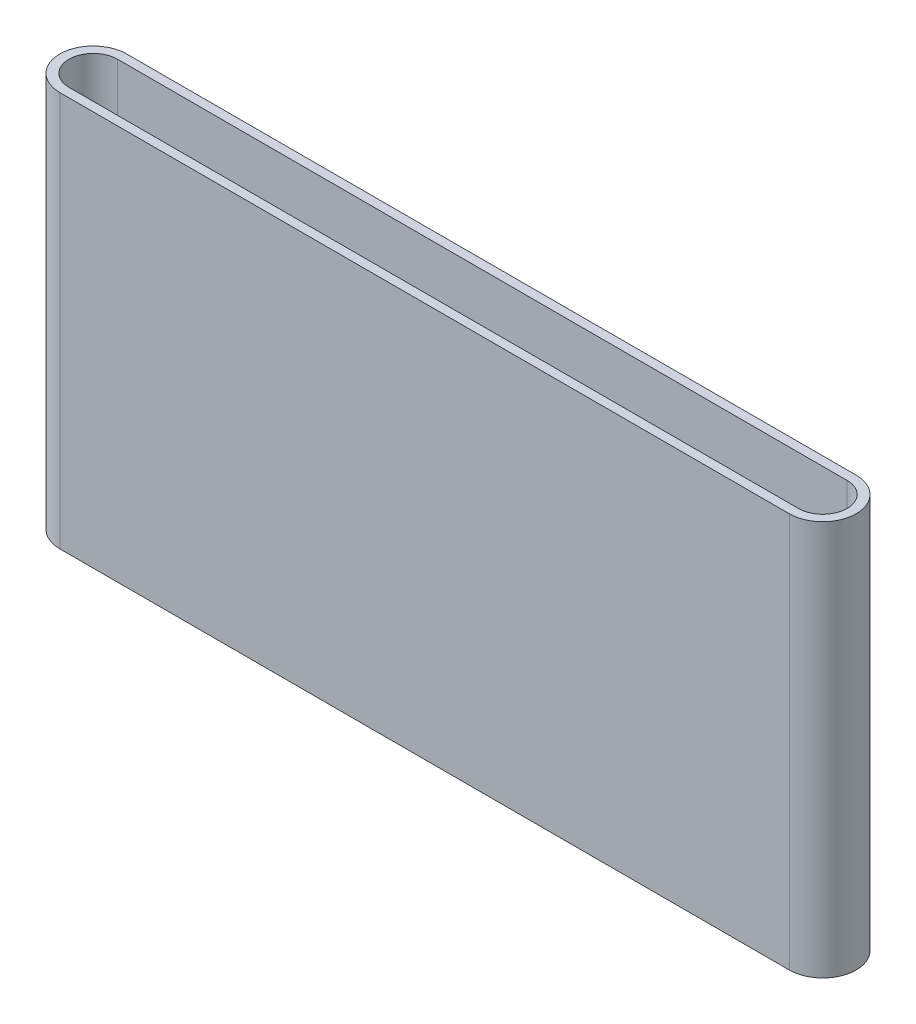
from build123d import *

# Parameters (mm, degrees)
BOSS_EXTRUDE1_DEPTH = 65


with BuildPart() as part:
    # Sketch1 → Boss-Extrude1 (new body)
    with BuildSketch(Plane(origin=(0, 0, 0), x_dir=(1, 0, 0), z_dir=(0, 1, 0))):
        with BuildLine():
            Line((0, 5.5), (120, 5.5))
            ThreePointArc((120, 5.5), (125.5, 0), (120, -5.5))
            Line((120, -5.5), (0, -5.5))
            ThreePointArc((0, -5.5), (-5.5, 0), (0, 5.5))
        make_face()
        with BuildLine():
            Line((0, 4), (120, 4))
            ThreePointArc((120, 4), (124, 0), (120, -4))
            Line((120, -4), (0, -4))
            ThreePointArc((0, -4), (-4, 0), (0, 4))
        make_face(mode=Mode.SUBTRACT)
    extrude(amount=BOSS_EXTRUDE1_DEPTH)


solid = part.part
